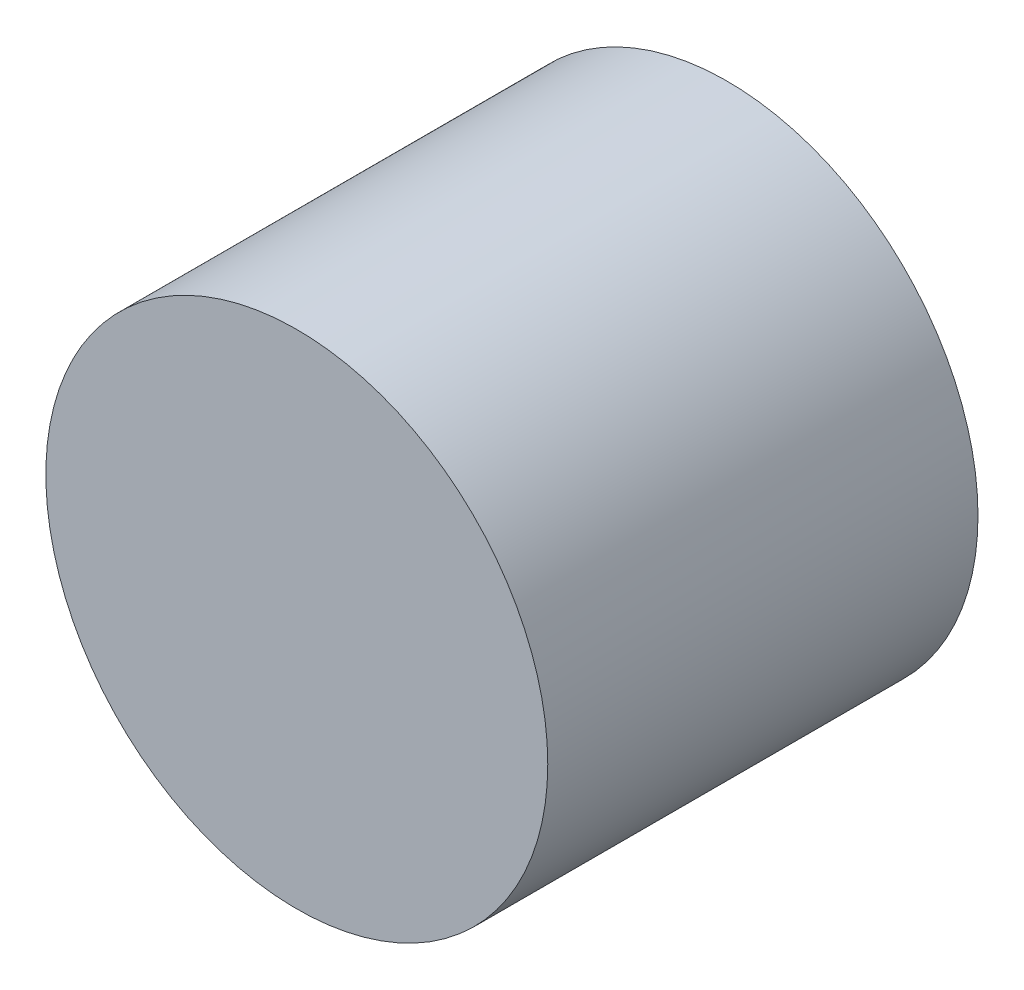
from build123d import *

# Parameters (mm, degrees)
SKETCH1_R           = 22.225
BOSS_EXTRUDE1_DEPTH = 38.1


with BuildPart() as part:
    # Sketch1 → Boss-Extrude1 (new body)
    with BuildSketch(Plane.XY):
        Circle(SKETCH1_R)
    extrude(amount=BOSS_EXTRUDE1_DEPTH)


solid = part.part
